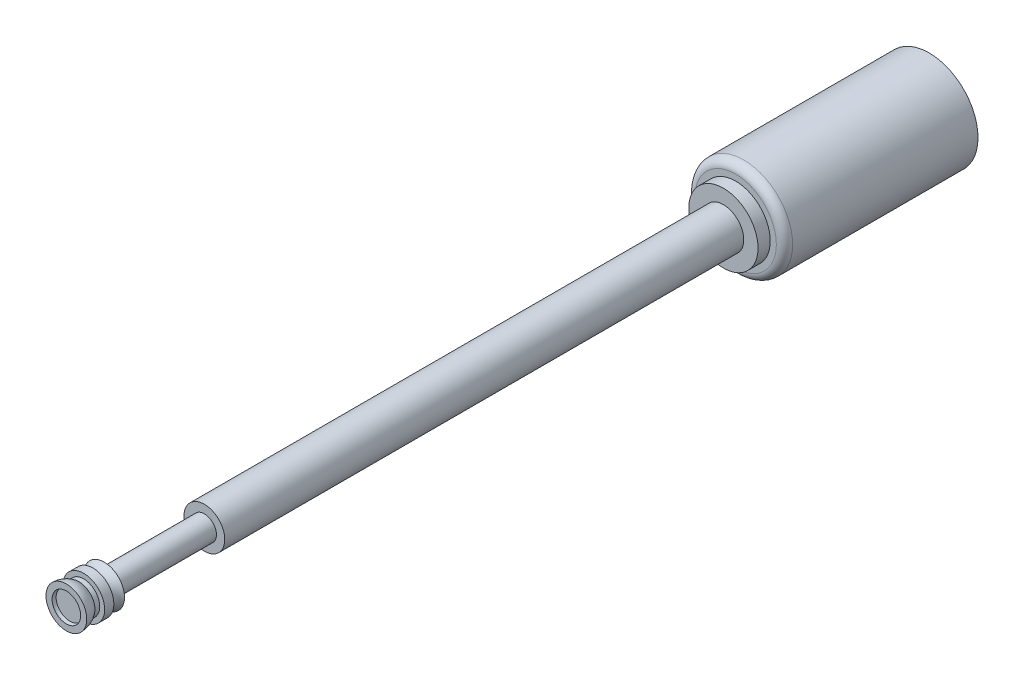
from build123d import *

# Parameters (mm, degrees)
SKETCH1_R           = 0.5
BOSS_EXTRUDE1_DEPTH = 15.5
SKETCH1_3_R         = 1.2
SKETCH1_3_R_2       = 0.5
BOSS_EXTRUDE2_DEPTH = 4.75
FILLET1_R           = 0.2
SKETCH2_R           = 0.85
BOSS_EXTRUDE3_DEPTH = 0.3
SKETCH4_W           = 0.465575533
SKETCH4_H           = 0.034477487
SKETCH5_W           = 1.257485092
SKETCH5_H           = 2.46
SKETCH6_R           = 0.5
BOSS_EXTRUDE4_DEPTH = 2.84


with BuildPart() as part:
    # Sketch1 → Boss-Extrude1 (new body)
    with BuildSketch(Plane.XY):
        Circle(SKETCH1_R)
    extrude(amount=BOSS_EXTRUDE1_DEPTH)



with BuildPart() as body_2:
    # Sketch1_3 → Boss-Extrude2 (new body)
    with BuildSketch(Plane.XY):
        Circle(SKETCH1_3_R)
        Circle(SKETCH1_3_R_2, mode=Mode.SUBTRACT)
    extrude(amount=-BOSS_EXTRUDE2_DEPTH)

    # Fillet1
    fillet1_edges = [body_2.edges().sort_by_distance(p)[0] for p in [
        (-1.2, 0, 0),
    ]]
    fillet(fillet1_edges, radius=FILLET1_R)


with BuildPart() as part_1:
    add(part.part)

    add(body_2.part)  # Boss-Extrude3 merges body 2
    # Sketch2 → Boss-Extrude3 (add)
    with BuildSketch(Plane.XY):
        Circle(SKETCH2_R)
    extrude(amount=BOSS_EXTRUDE3_DEPTH)

    # Sketch3 → Revolve1 (revolve)
    with BuildSketch(Plane(origin=(0, 0, 0), x_dir=(1, 0, 0), z_dir=(0, 1, 0))):
        with BuildLine():
            Line((0.5, -15.5), (0, -15.5))
            Line((0, -15.5), (0, -16.0775))
            ThreePointArc((0, -16.0775), (0.247487373, -16.180012627), (0.35, -16.4275))
            Line((0.35, -16.4275), (0.5, -16.4275))
            ThreePointArc((0.5, -16.4275), (0.472905202, -16.265140307), (0.39455732, -16.120377026))
            Line((0.39455732, -16.120377026), (0.39455732, -16.001977042))
            Line((0.39455732, -16.001977042), (0.513344718, -16.001977042))
            Line((0.513344718, -16.001977042), (0.513344718, -15.7758978))
            Line((0.513344718, -15.7758978), (0.386893617, -15.7758978))
            ThreePointArc((0.386893617, -15.7758978), (0.416267844, -15.626806679), (0.5, -15.5))
        make_face()
    revolve(axis=Axis((0, 0, 15.5), (0, 0, 1)))

    # Sketch4 → Revolve2 (revolve)
    with BuildSketch(Plane(origin=(0, 0, 0), x_dir=(1, 0, 0), z_dir=(0, 1, 0))):
        with Locations((-0.232787767, -16.322761257)):
            Rectangle(SKETCH4_W, SKETCH4_H)
    revolve(axis=Axis((0, 0, 16.305522513), (0, 0, 1)))

    # Sketch5 → Cut-Revolve1 (revolve, cut)
    with BuildSketch(Plane(origin=(0, 0, 0), x_dir=(1, 0, 0), z_dir=(0, 1, 0))):
        with Locations((-0.924942546, -14.27)):
            Rectangle(SKETCH5_W, SKETCH5_H)
    revolve(axis=Axis((0, 0, 15.5), (0, 0, 1)), mode=Mode.SUBTRACT)

    # Sketch6 → Boss-Extrude4 (add)
    with BuildSketch(Plane(origin=(0, 0, -4.75), x_dir=(-1, 0, 0), z_dir=(0, 0, -1))):
        Circle(SKETCH6_R)
    extrude(amount=-BOSS_EXTRUDE4_DEPTH)


solid = part_1.part
